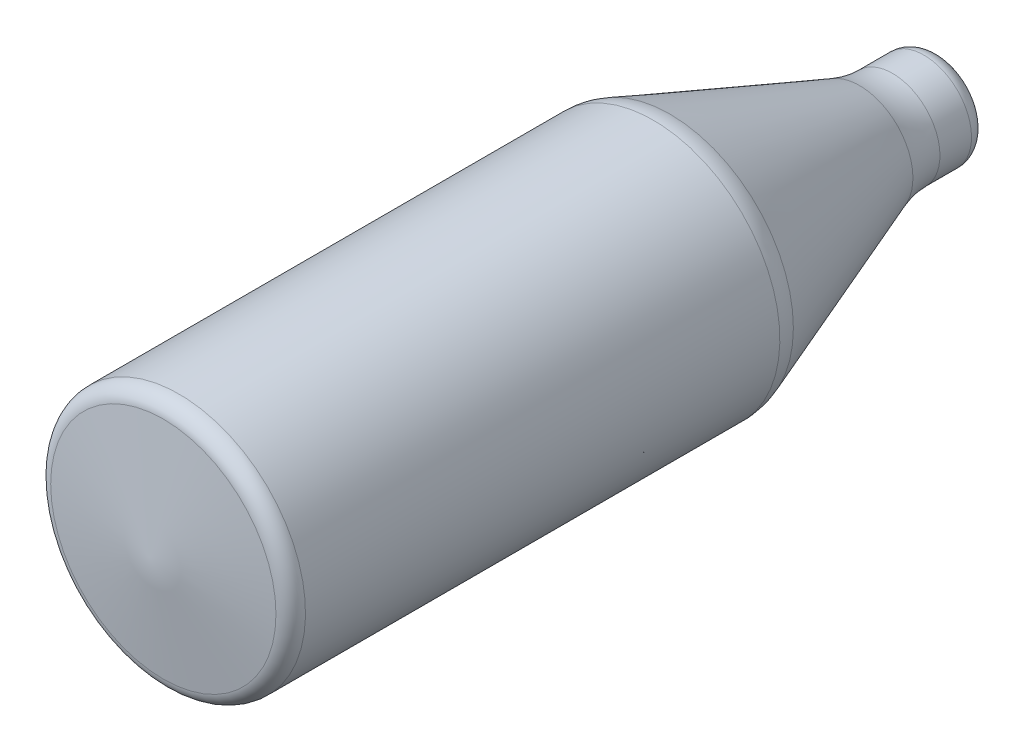
from build123d import *


with BuildPart() as part:
    # Sketch1 → Revolve2 (revolve)
    with BuildSketch(Plane(origin=(0, 0, 0), x_dir=(0, 0, -1), z_dir=(1, 0, 0)), mode=Mode.PRIVATE) as revolve2_sk:
        with BuildLine():
            Line((310.023918284, 20), (310.023918284, 0))
            Line((310.023918284, 0), (320.023918284, 0))
            Line((320.023918284, 0), (320.023918284, 20))
            ThreePointArc((320.023918284, 20), (317.094986096, 27.071067812), (310.023918284, 30))
            Line((310.023918284, 30), (290.064881334, 30))
            ThreePointArc((290.064881334, 30), (279.487694994, 30.939665349), (269.24180917, 33.729229029))
            Line((269.24180917, 33.729229029), (149.24180917, 78.135385485))
            ThreePointArc((149.24180917, 78.135385485), (144.118866258, 79.530167326), (138.830273088, 80))
            Line((138.830273088, 80), (-161.169726912, 80))
            ThreePointArc((-161.169726912, 80), (-167.788864689, 77.49579983), (-171.092873277, 71.237403019))
            Line((-171.092873277, 71.237403019), (-179.976081716, 0))
            Line((-179.976081716, 0), (-169.898632858, 0))
            Line((-169.898632858, 0), (-161.169726912, 70))
            Line((-161.169726912, 70), (138.830273088, 70))
            ThreePointArc((138.830273088, 70), (142.356001868, 69.686778217), (145.771297142, 68.756923657))
            Line((145.771297142, 68.756923657), (265.771297142, 24.350767201))
            ThreePointArc((265.771297142, 24.350767201), (277.724830603, 21.09627624), (290.064881334, 20))
            Line((290.064881334, 20), (310.023918284, 20))
        make_face()
    revolve(revolve2_sk.sketch.rotate(Axis((0, 0, 179.976081716), (0, 0, -1)), 180), axis=Axis((0, 0, 179.976081716), (0, 0, -1)))


solid = part.part
